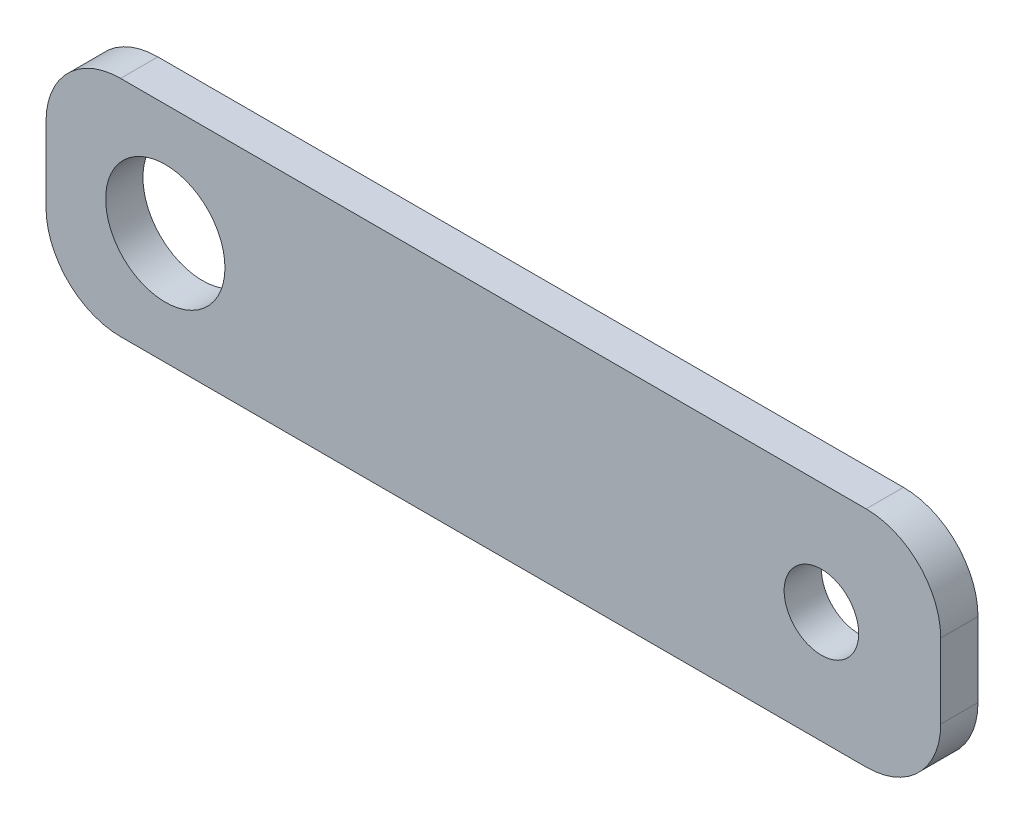
from build123d import *

# Parameters (mm, degrees)
ESQUISSE1_W             = 120
ESQUISSE1_H             = 30
BOSS_EXTRU_1_DEPTH      = 5
ESQUISSE2_R             = 8
ESQUISSE2_R_2           = 5
ENL_V_MAT_EXTRU_1_DEPTH = 10
CONG_1_R                = 10


with BuildPart() as part:
    # Esquisse1 → Boss.-Extru.1 (new body)
    with BuildSketch(Plane.XY):
        Rectangle(ESQUISSE1_W, ESQUISSE1_H)
    extrude(amount=BOSS_EXTRU_1_DEPTH)

    # Esquisse2 → Enlèv. mat.-Extru.1 (cut)
    with BuildSketch(Plane.XY.offset(5)):
        with Locations((-44, 0)):
            Circle(ESQUISSE2_R)
        with Locations((44, 0)):
            Circle(ESQUISSE2_R_2)
    extrude(amount=-ENL_V_MAT_EXTRU_1_DEPTH, mode=Mode.SUBTRACT)

    # Congé1
    cong_1_edges = [part.edges().sort_by_distance(p)[0] for p in [
        (-60, 15, 2.5),
        (60, 15, 2.5),
        (60, -15, 2.5),
        (-60, -15, 2.5),
    ]]
    fillet(cong_1_edges, radius=CONG_1_R)


solid = part.part
